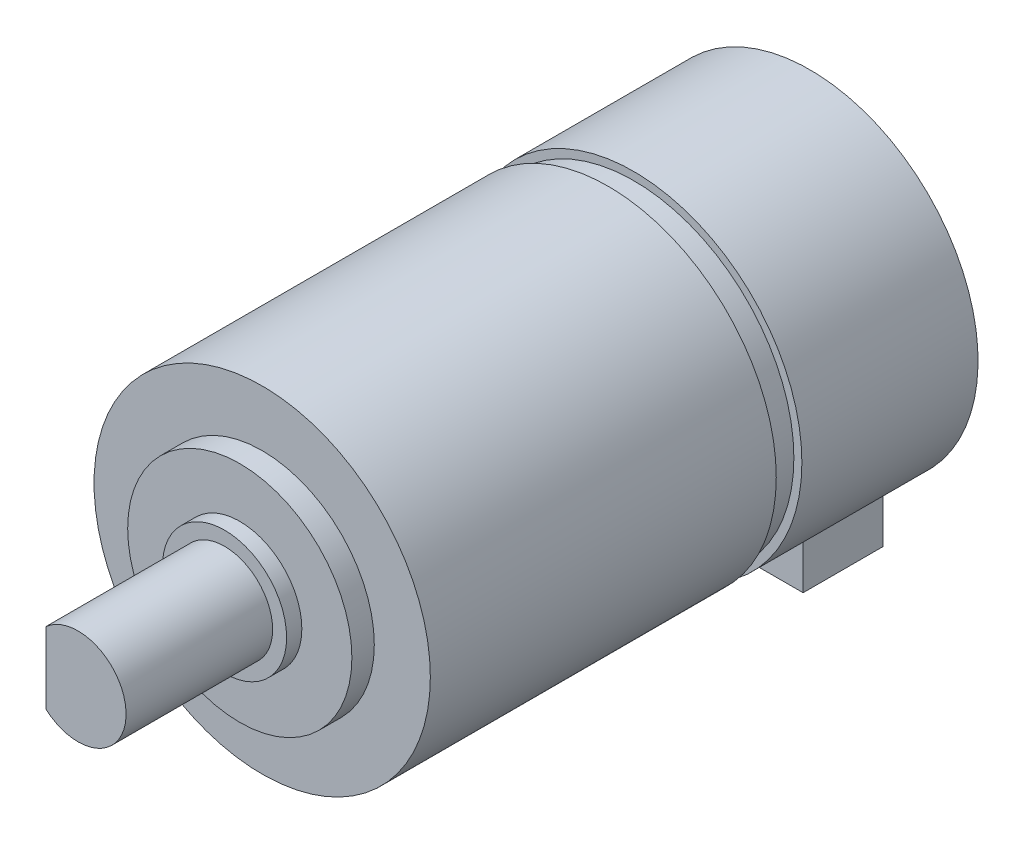
from build123d import *

# Parameters (mm, degrees)
ESQUISSE1_R        = 21
BOSS_EXTRU_1_DEPTH = 22
BOSS_EXTRU_2_DEPTH = 10
ESQUISSE3_R        = 20
BOSS_EXTRU_3_DEPTH = 3.2
ESQUISSE4_R        = 21
BOSS_EXTRU_4_DEPTH = 43.2
ESQUISSE5_R        = 14
BOSS_EXTRU_5_DEPTH = 2.8
ESQUISSE6_R        = 7.75
BOSS_EXTRU_6_DEPTH = 1.9
ESQUISSE7_R        = 6
BOSS_EXTRU_7_DEPTH = 7.8
BOSS_EXTRU_8_DEPTH = 10.5


with BuildPart() as part:
    # Esquisse1 → Boss.-Extru.1 (new body)
    with BuildSketch(Plane.XY):
        Circle(ESQUISSE1_R)
    extrude(amount=BOSS_EXTRU_1_DEPTH)

    # Esquisse2 → Boss.-Extru.2 (add)
    with BuildSketch(Plane(origin=(0, 0, 0), x_dir=(-1, 0, 0), z_dir=(0, 0, -1))):
        with BuildLine():
            ThreePointArc((9.15, -18.90178563), (0, -21), (-9.15, -18.90178563))
            Line((-9.15, -18.90178563), (-9.15, -26))
            Line((-9.15, -26), (9.15, -26))
            Line((9.15, -26), (9.15, -18.90178563))
        make_face()
    extrude(amount=-BOSS_EXTRU_2_DEPTH)

    # Esquisse3 → Boss.-Extru.3 (add)
    with BuildSketch(Plane.XY.offset(22)):
        Circle(ESQUISSE3_R)
    extrude(amount=BOSS_EXTRU_3_DEPTH)

    # Esquisse4 → Boss.-Extru.4 (add)
    with BuildSketch(Plane.XY.offset(25.2)):
        Circle(ESQUISSE4_R)
    extrude(amount=BOSS_EXTRU_4_DEPTH)

    # Esquisse5 → Boss.-Extru.5 (add)
    with BuildSketch(Plane.XY.offset(68.4)):
        Circle(ESQUISSE5_R)
    extrude(amount=BOSS_EXTRU_5_DEPTH)

    # Esquisse6 → Boss.-Extru.6 (add)
    with BuildSketch(Plane.XY.offset(71.2)):
        Circle(ESQUISSE6_R)
    extrude(amount=BOSS_EXTRU_6_DEPTH)

    # Esquisse7 → Boss.-Extru.7 (add)
    with BuildSketch(Plane.XY.offset(73.1)):
        Circle(ESQUISSE7_R)
    extrude(amount=BOSS_EXTRU_7_DEPTH)

    # Esquisse8 → Boss.-Extru.8 (add)
    with BuildSketch(Plane.XY.offset(80.9)):
        with BuildLine():
            ThreePointArc((6, 0), (2.449489743, 5.477225575), (-4, 4.472135955))
            Line((-4, 4.472135955), (-4, -4.472135955))
            ThreePointArc((-4, -4.472135955), (2.449489743, -5.477225575), (6, 0))
        make_face()
    extrude(amount=BOSS_EXTRU_8_DEPTH)


solid = part.part
